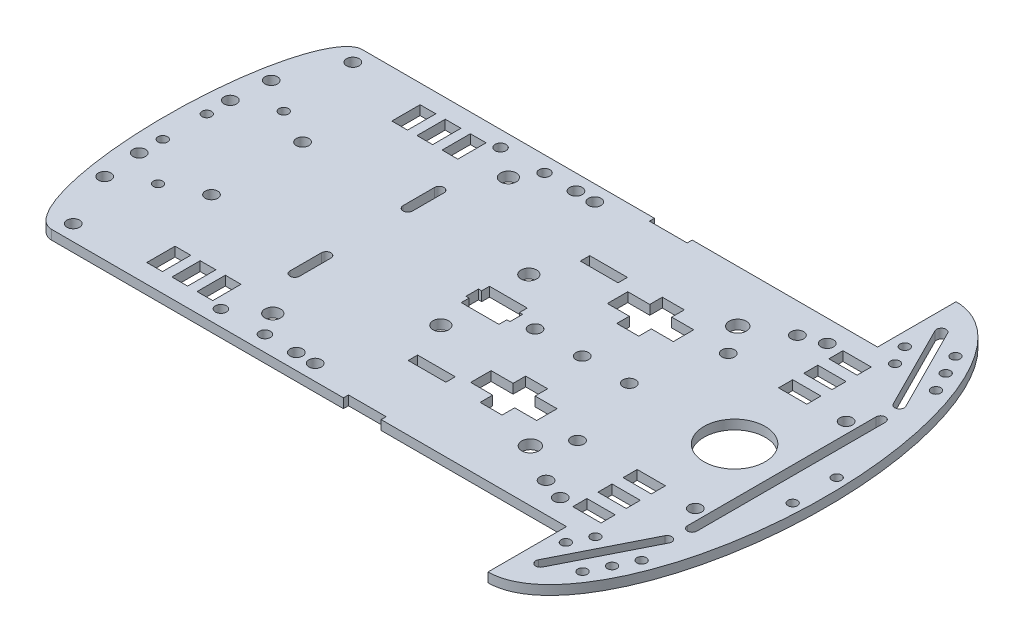
from build123d import *

# Parameters (mm, degrees)
SKETCH1_W           = 210
SKETCH1_H           = 149
BOSS_EXTRUDE1_DEPTH = 3
SKETCH2_W           = 177
SKETCH2_H           = 25
CUT_EXTRUDE1_DEPTH  = 3
SKETCH3_W           = 12
SKETCH3_H           = 3
SKETCH3_W_2         = 7
SKETCH3_H_2         = 6.5
SKETCH3_H_3         = 4
SKETCH3_R           = 2
SKETCH3_R_2         = 2.75
SKETCH3_W_3         = 9
SKETCH3_H_4         = 4.5
SKETCH3_H_5         = 1.6
SKETCH3_H_6         = 14.5
SKETCH3_W_4         = 21
CUT_EXTRUDE2_DEPTH  = 3
SKETCH4_R           = 2
SKETCH4_R_2         = 1.75
SKETCH4_R_3         = 2.5
CUT_EXTRUDE3_DEPTH  = 3
SKETCH5_W           = 5
SKETCH5_H           = 9
CUT_EXTRUDE4_DEPTH  = 3
SKETCH7_R           = 9.75
SKETCH7_R_2         = 2
SKETCH7_R_3         = 2.5
SKETCH7_W           = 12
SKETCH7_H           = 9
SKETCH7_W_2         = 14
SKETCH7_H_2         = 4
CUT_EXTRUDE5_DEPTH  = 3
SKETCH6_R           = 2
SKETCH6_R_2         = 1.5
CUT_EXTRUDE6_DEPTH  = 3
CUT_EXTRUDE7_DEPTH  = 3
SKETCH9_R           = 1.5
SKETCH9_R_2         = 2
CUT_EXTRUDE8_DEPTH  = 3
CUT_EXTRUDE9_DEPTH  = 3
CUT_EXTRUDE10_DEPTH = 3


with BuildPart() as part:
    # Sketch1 → Boss-Extrude1 (new body)
    with BuildSketch(Plane(origin=(0, 0, 0), x_dir=(1, 0, 0), z_dir=(0, 1, 0))):
        with Locations((105, 74.5)):
            Rectangle(SKETCH1_W, SKETCH1_H)
    extrude(amount=BOSS_EXTRUDE1_DEPTH)

    # Sketch2 → Cut-Extrude1 (cut)
    with BuildSketch(Plane(origin=(0, 3, 0), x_dir=(1, 0, 0), z_dir=(0, 1, 0))):
        with Locations((88.5, 136.5)):
            Rectangle(SKETCH2_W, SKETCH2_H)
        with Locations((88.5, 12.5)):
            Rectangle(SKETCH2_W, SKETCH2_H)
    extrude(amount=-CUT_EXTRUDE1_DEPTH, mode=Mode.SUBTRACT)

    # Sketch3 → Cut-Extrude2 (cut)
    with BuildSketch(Plane(origin=(0, 3, 0), x_dir=(1, 0, 0), z_dir=(0, 1, 0))):
        with Locations((112, 101.9)):
            Rectangle(SKETCH3_W, SKETCH3_H)
        with Locations((125.5, 96.25)):
            Rectangle(SKETCH3_W_2, SKETCH3_H_2)
        with Locations((132.5, 96.25)):
            Rectangle(SKETCH3_W_2, SKETCH3_H_2)
        with Locations((139.5, 96.25)):
            Rectangle(SKETCH3_W_2, SKETCH3_H_2)
        with Locations((132.5, 91)):
            Rectangle(SKETCH3_W_2, SKETCH3_H_3)
        with Locations((132.5, 101.5)):
            Rectangle(SKETCH3_W_2, SKETCH3_H_3)
        with Locations((155, 98.5)):
            Circle(SKETCH3_R)
        with Locations((149, 107.5)):
            Circle(SKETCH3_R_2)
        with Locations((161, 114.5)):
            Circle(SKETCH3_R)
        with Locations((168, 117)):
            Circle(SKETCH3_R)
        with Locations((177, 115.25)):
            Rectangle(SKETCH3_W_3, SKETCH3_H_4)
        with Locations((177, 107.25)):
            Rectangle(SKETCH3_W_3, SKETCH3_H_4)
        with Locations((177, 99.25)):
            Rectangle(SKETCH3_W_3, SKETCH3_H_4)
        with Locations((112, 47.1)):
            Rectangle(SKETCH3_W, SKETCH3_H)
        with Locations((112, 123.2)):
            Rectangle(SKETCH3_W, SKETCH3_H_5)
        with Locations((112, 25.8)):
            Rectangle(SKETCH3_W, SKETCH3_H_5)
        with Locations((132.5, 52.75)):
            Rectangle(SKETCH3_W_2, SKETCH3_H_6)
        with Locations((132.5, 52.75)):
            Rectangle(SKETCH3_W_4, SKETCH3_H_2)
        with Locations((149, 41.5)):
            Circle(SKETCH3_R_2)
        with Locations((155, 50.5)):
            Circle(SKETCH3_R)
        with Locations((161, 34.5)):
            Circle(SKETCH3_R)
        with Locations((168, 32)):
            Circle(SKETCH3_R)
        with Locations((177, 49.75)):
            Rectangle(SKETCH3_W_3, SKETCH3_H_4)
        with Locations((177, 41.75)):
            Rectangle(SKETCH3_W_3, SKETCH3_H_4)
        with Locations((177, 33.75)):
            Rectangle(SKETCH3_W_3, SKETCH3_H_4)
    extrude(amount=-CUT_EXTRUDE2_DEPTH, mode=Mode.SUBTRACT)

    # Sketch4 → Cut-Extrude3 (cut)
    with BuildSketch(Plane(origin=(0, 3, 0), x_dir=(1, 0, 0), z_dir=(0, 1, 0))):
        with Locations((92, 119)):
            Circle(SKETCH4_R)
        with Locations((86, 119)):
            Circle(SKETCH4_R)
        with Locations((76, 119)):
            Circle(SKETCH4_R_2)
        with Locations((62, 119)):
            Circle(SKETCH4_R_2)
        with Locations((71.5, 112)):
            Circle(SKETCH4_R_3)
        with Locations((71.5, 37)):
            Circle(SKETCH4_R_3)
        with Locations((62, 30)):
            Circle(SKETCH4_R_2)
        with Locations((76, 30)):
            Circle(SKETCH4_R_2)
        with Locations((86, 30)):
            Circle(SKETCH4_R)
        with Locations((92, 30)):
            Circle(SKETCH4_R)
        with Locations((15, 119)):
            Circle(SKETCH4_R)
        with Locations((15, 30)):
            Circle(SKETCH4_R)
    extrude(amount=-CUT_EXTRUDE3_DEPTH, mode=Mode.SUBTRACT)

    # Sketch5 → Cut-Extrude4 (cut)
    with BuildSketch(Plane(origin=(0, 3, 0), x_dir=(1, 0, 0), z_dir=(0, 1, 0))):
        with Locations((55.9, 113.5)):
            Rectangle(SKETCH5_W, SKETCH5_H)
        with Locations((47.9, 113.5)):
            Rectangle(SKETCH5_W, SKETCH5_H)
        with Locations((39.9, 113.5)):
            Rectangle(SKETCH5_W, SKETCH5_H)
        with Locations((39.9, 35.5)):
            Rectangle(SKETCH5_W, SKETCH5_H)
        with Locations((47.9, 35.5)):
            Rectangle(SKETCH5_W, SKETCH5_H)
        with Locations((55.9, 35.5)):
            Rectangle(SKETCH5_W, SKETCH5_H)
    extrude(amount=-CUT_EXTRUDE4_DEPTH, mode=Mode.SUBTRACT)

    # Sketch7 → Cut-Extrude5 (cut)
    with BuildSketch(Plane(origin=(0, 3, 0), x_dir=(1, 0, 0), z_dir=(0, 1, 0))):
        with Locations((181, 74.5)):
            Circle(SKETCH7_R)
        with Locations((132.5, 74.5)):
            Circle(SKETCH7_R_2)
        with Locations((147.5, 74.5)):
            Circle(SKETCH7_R_2)
        with Locations((117.5, 74.5)):
            Circle(SKETCH7_R_2)
        with Locations((101.5, 88.5)):
            Circle(SKETCH7_R_3)
        with Locations((101.5, 60.5)):
            Circle(SKETCH7_R_3)
        with Locations((104.5, 74.5)):
            Rectangle(SKETCH7_W, SKETCH7_H)
        with Locations((104.5, 74.5)):
            Rectangle(SKETCH7_W_2, SKETCH7_H_2)
    extrude(amount=-CUT_EXTRUDE5_DEPTH, mode=Mode.SUBTRACT)

    # Sketch6 → Cut-Extrude6 (cut)
    with BuildSketch(Plane(origin=(0, 3, 0), x_dir=(1, 0, 0), z_dir=(0, 1, 0))):
        with Locations((6, 89)):
            Circle(SKETCH6_R)
        with Locations((29, 89)):
            Circle(SKETCH6_R)
        with Locations((29, 60)):
            Circle(SKETCH6_R)
        with Locations((6, 60)):
            Circle(SKETCH6_R)
        with Locations((6, 81.5)):
            Circle(SKETCH6_R_2)
        with Locations((6, 67.5)):
            Circle(SKETCH6_R_2)
        with Locations((7, 48)):
            Circle(SKETCH6_R)
        with Locations((17.5, 54.5)):
            Circle(SKETCH6_R_2)
        with Locations((17.5, 94.5)):
            Circle(SKETCH6_R_2)
        with Locations((7, 101)):
            Circle(SKETCH6_R)
    extrude(amount=-CUT_EXTRUDE6_DEPTH, mode=Mode.SUBTRACT)

    # Sketch8 → Cut-Extrude7 (cut)
    with BuildSketch(Plane(origin=(0, 3, 0), x_dir=(1, 0, 0), z_dir=(0, 1, 0))):
        with BuildLine():
            Line((65.5, 97.5), (65.5, 87.5))
            ThreePointArc((65.5, 87.5), (64, 86), (62.5, 87.5))
            Line((62.5, 87.5), (62.5, 97.5))
            ThreePointArc((62.5, 97.5), (64, 99), (65.5, 97.5))
        make_face()
        with BuildLine():
            Line((65.5, 51.5), (65.5, 61.5))
            ThreePointArc((65.5, 61.5), (64, 63), (62.5, 61.5))
            Line((62.5, 61.5), (62.5, 51.5))
            ThreePointArc((62.5, 51.5), (64, 50), (65.5, 51.5))
        make_face()
    extrude(amount=-CUT_EXTRUDE7_DEPTH, mode=Mode.SUBTRACT)

    # Sketch9 → Cut-Extrude8 (cut)
    with BuildSketch(Plane(origin=(0, 3, 0), x_dir=(1, 0, 0), z_dir=(0, 1, 0))):
        with Locations((195.10817133, 127.595428325)):
            Circle(SKETCH9_R)
        with Locations((191.95817133, 133.846628209)):
            Circle(SKETCH9_R)
        with Locations((198.25817133, 121.34422844)):
            Circle(SKETCH9_R)
        with Locations((184.39182867, 122.195428325)):
            Circle(SKETCH9_R)
        with Locations((181.24182867, 128.446628209)):
            Circle(SKETCH9_R)
        with Locations((192.5, 98.5)):
            Circle(SKETCH9_R_2)
        with Locations((206.5, 81.5)):
            Circle(SKETCH9_R)
        with Locations((192.5, 50.5)):
            Circle(SKETCH9_R_2)
        with Locations((184.39182867, 26.804571675)):
            Circle(SKETCH9_R)
        with Locations((181.24182867, 20.553371791)):
            Circle(SKETCH9_R)
        with Locations((191.95817133, 15.153371791)):
            Circle(SKETCH9_R)
        with Locations((195.10817133, 21.404571675)):
            Circle(SKETCH9_R)
        with Locations((198.25817133, 27.65577156)):
            Circle(SKETCH9_R)
        with Locations((206.5, 67.5)):
            Circle(SKETCH9_R)
        with BuildLine():
            Line((199, 104.5), (199, 44.5))
            ThreePointArc((199, 44.5), (197.5, 43), (196, 44.5))
            Line((196, 44.5), (196, 104.5))
            ThreePointArc((196, 104.5), (197.5, 106), (199, 104.5))
        make_face()
        with BuildLine():
            Line((195.160457168, 110.825), (181.660457168, 137.615856649))
            ThreePointArc((181.660457168, 137.615856649), (182.325, 139.630399482), (184.339542832, 138.965856649))
            Line((184.339542832, 138.965856649), (197.839542832, 112.175))
            ThreePointArc((197.839542832, 112.175), (197.175, 110.160457168), (195.160457168, 110.825))
        make_face()
        with BuildLine():
            Line((195.160457168, 38.175), (181.660457168, 11.384143351))
            ThreePointArc((181.660457168, 11.384143351), (182.325, 9.369600518), (184.339542832, 10.034143351))
            Line((184.339542832, 10.034143351), (197.839542832, 36.825))
            ThreePointArc((197.839542832, 36.825), (197.175, 38.839542832), (195.160457168, 38.175))
        make_face()
    extrude(amount=-CUT_EXTRUDE8_DEPTH, mode=Mode.SUBTRACT)

    # Sketch11 → Cut-Extrude9 (cut)
    with BuildSketch(Plane(origin=(0, 3, 0), x_dir=(1, 0, 0), z_dir=(0, 1, 0))):
        with BuildLine():
            Line((210, 149), (177, 149))
            add(Edge.make_bspline(
                [(210, 74.5), (210, 149), (177, 149)],
                knots=[4.71238898, 4.71238898, 4.71238898, 6.283185307, 6.283185307, 6.283185307], degree=2, weights=[1, 0.707106781, 1]))
            Line((210, 74.5), (210, 149))
        make_face()
        with BuildLine():
            add(Edge.make_bspline(
                [(177, 0), (210, 0), (210, 74.5)],
                knots=[3.141592654, 3.141592654, 3.141592654, 4.71238898, 4.71238898, 4.71238898], degree=2, weights=[1, 0.707106781, 1]))
            Line((177, 0), (210, 0))
            Line((210, 0), (210, 74.5))
        make_face()
    extrude(amount=-CUT_EXTRUDE9_DEPTH, mode=Mode.SUBTRACT)

    # Sketch12 → Cut-Extrude10 (cut)
    with BuildSketch(Plane(origin=(0, 3, 0), x_dir=(1, 0, 0), z_dir=(0, 1, 0))):
        with BuildLine():
            add(Edge.make_bspline(
                [(13, 124), (0, 124), (0, 74.5)],
                knots=[0, 0, 0, 1.570796327, 1.570796327, 1.570796327], degree=2, weights=[1, 0.707106781, 1]))
            Line((13, 124), (0, 124))
            Line((0, 124), (0, 74.5))
        make_face()
        with BuildLine():
            add(Edge.make_bspline(
                [(0, 74.5), (0, 25), (13, 25)],
                knots=[1.570796327, 1.570796327, 1.570796327, 3.141592654, 3.141592654, 3.141592654], degree=2, weights=[1, 0.707106781, 1]))
            Line((0, 74.5), (0, 25))
            Line((0, 25), (13, 25))
        make_face()
    extrude(amount=-CUT_EXTRUDE10_DEPTH, mode=Mode.SUBTRACT)


solid = part.part
